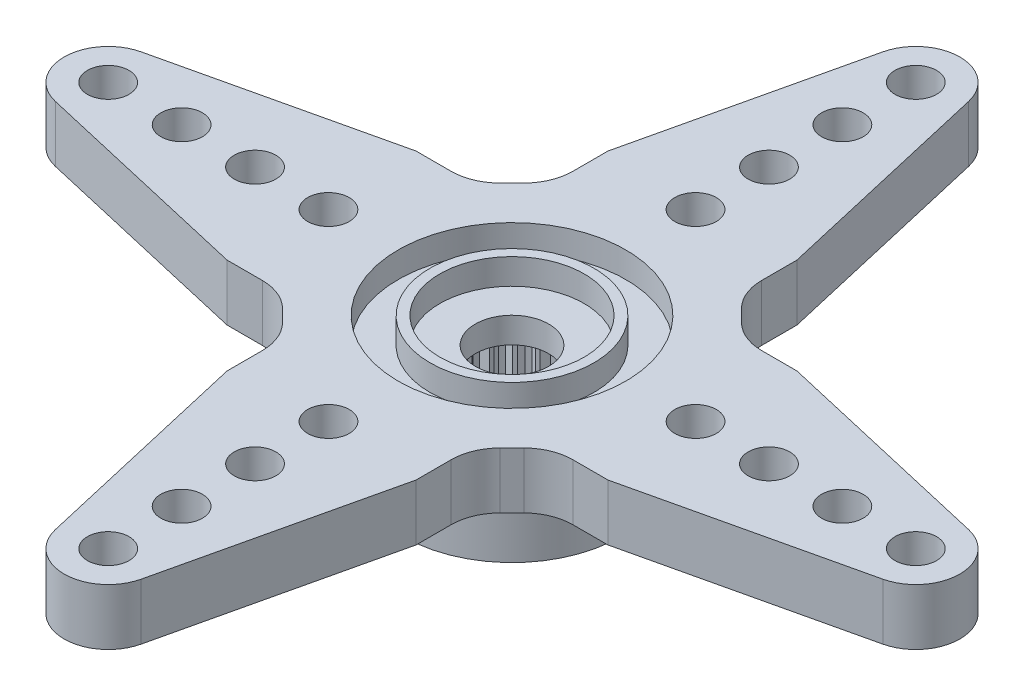
from build123d import *

# Parameters (mm, degrees)
ESQUISSE2_W                  = 4.45
ESQUISSE2_H                  = 5.6
ESQUISSE3_R                  = 0.85
BOSS_EXTRU_1_DEPTH           = 2.3
R_P_TITION_CIRCULAIRE2_COUNT = 4
ESQUISSE4_R                  = 2.95
ENL_V_MAT_EXTRU_1_DEPTH      = 1.05
ESQUISSE5_R                  = 4.65
ESQUISSE5_R_2                = 3.35
ENL_V_MAT_EXTRU_2_DEPTH      = 1.05
ESQUISSE6_R                  = 1.5
ENL_V_MAT_EXTRU_3_DEPTH      = 6.6
ESQUISSE8_R                  = 2.68
ENL_V_MAT_EXTRU_4_DEPTH      = 4.5
ENL_V_MAT_EXTRU_5_DEPTH      = 4.5
R_P_TITION_CIRCULAIRE1_COUNT = 25


with BuildPart() as part:
    # Esquisse2 → Révolution1 (revolve)
    with BuildSketch(Plane.XY):
        with Locations((-2.225, -0.7)):
            Rectangle(ESQUISSE2_W, ESQUISSE2_H)
    revolve(axis=Axis((0, 3.929571688, 0), (0, -1, 0)))

    # Esquisse3 → Boss.-Extru.1 (add)
    with BuildSketch(Plane(origin=(0, 2.1, 0), x_dir=(1, 0, 0), z_dir=(0, 1, 0))):
        with BuildLine():
            Line((-16.904911898, 1.753866117), (-7.782243794, 3.86))
            Line((-7.782243794, 3.86), (-6.344663043, 3.86))
            ThreePointArc((-6.344663043, 3.86), (-5.579296179, 4.012240935), (-4.930449481, 4.445786438))
            Line((-4.930449481, 4.445786438), (-4.688117959, 4.688117959))
            Line((-4.688117959, 4.688117959), (0, 4.688117959))
            Line((0, 4.688117959), (0, -4.688117959))
            Line((0, -4.688117959), (-4.688117959, -4.688117959))
            Line((-4.688117959, -4.688117959), (-4.930449481, -4.445786438))
            ThreePointArc((-4.930449481, -4.445786438), (-5.579296179, -4.012240935), (-6.344663043, -3.86))
            Line((-6.344663043, -3.86), (-7.782243794, -3.86))
            Line((-7.782243794, -3.86), (-16.904911898, -1.753866117))
            ThreePointArc((-16.904911898, -1.753866117), (-18.3, 0), (-16.904911898, 1.753866117))
        make_face()
        with Locations((-16.5, 0)):
            Circle(ESQUISSE3_R, mode=Mode.SUBTRACT)
        with Locations((-13.5, 0)):
            Circle(ESQUISSE3_R, mode=Mode.SUBTRACT)
        with Locations((-10.5, 0)):
            Circle(ESQUISSE3_R, mode=Mode.SUBTRACT)
        with Locations((-7.5, 0)):
            Circle(ESQUISSE3_R, mode=Mode.SUBTRACT)
    boss_extru_1 = extrude(amount=-BOSS_EXTRU_1_DEPTH)

    # Répétition circulaire2: Boss.-Extru.1 ×4 about axis
    r_p_tition_circulaire2_axis = Axis((0, 0, 0), (0, 1, 0))
    for i in range(1, R_P_TITION_CIRCULAIRE2_COUNT):
        add(boss_extru_1.rotate(r_p_tition_circulaire2_axis, i * 360 / R_P_TITION_CIRCULAIRE2_COUNT))

    # Esquisse4 → Enlèv. mat.-Extru.1 (cut)
    with BuildSketch(Plane(origin=(0, 2.1, 0), x_dir=(1, 0, 0), z_dir=(0, 1, 0))):
        Circle(ESQUISSE4_R)
    extrude(amount=-ENL_V_MAT_EXTRU_1_DEPTH, mode=Mode.SUBTRACT)

    # Esquisse5 → Enlèv. mat.-Extru.2 (cut)
    with BuildSketch(Plane(origin=(0, 2.1, 0), x_dir=(1, 0, 0), z_dir=(0, 1, 0))):
        Circle(ESQUISSE5_R)
        Circle(ESQUISSE5_R_2, mode=Mode.SUBTRACT)
    extrude(amount=-ENL_V_MAT_EXTRU_2_DEPTH, mode=Mode.SUBTRACT)

    # Esquisse6 → Enlèv. mat.-Extru.3 (cut, through all)
    with BuildSketch(Plane.XZ.offset(3.5)):
        Circle(ESQUISSE6_R)
    extrude(amount=-ENL_V_MAT_EXTRU_3_DEPTH, mode=Mode.SUBTRACT)

    # Esquisse8 → Enlèv. mat.-Extru.4 (cut, through all)
    with BuildSketch(Plane(origin=(0, 0, 0), x_dir=(1, 0, 0), z_dir=(0, 1, 0))):
        Circle(ESQUISSE8_R)
    extrude(amount=-ENL_V_MAT_EXTRU_4_DEPTH, mode=Mode.SUBTRACT)

    # Esquisse9 → Enlèv. mat.-Extru.5 (cut, through all)
    with BuildSketch(Plane(origin=(0, 0, 0), x_dir=(1, 0, 0), z_dir=(0, 1, 0))):
        with BuildLine():
            Line((0.10528472, -3.048182266), (0.265600366, -2.666806413))
            ThreePointArc((0.265600366, -2.666806413), (0, -2.68), (-0.265600366, -2.666806413))
            Line((-0.265600366, -2.666806413), (-0.10528472, -3.048182266))
            ThreePointArc((-0.10528472, -3.048182266), (0, -3.05), (0.10528472, -3.048182266))
        make_face()
    enl_v_mat_extru_5 = extrude(amount=-ENL_V_MAT_EXTRU_5_DEPTH, mode=Mode.SUBTRACT)

    # Répétition circulaire1: Enlèv. mat.-Extru.5 ×25 about axis
    r_p_tition_circulaire1_axis = Axis((0, 0, 0), (0, 1, 0))
    for i in range(1, R_P_TITION_CIRCULAIRE1_COUNT):
        add(enl_v_mat_extru_5.rotate(r_p_tition_circulaire1_axis, i * 360 / R_P_TITION_CIRCULAIRE1_COUNT), mode=Mode.SUBTRACT)


solid = part.part
